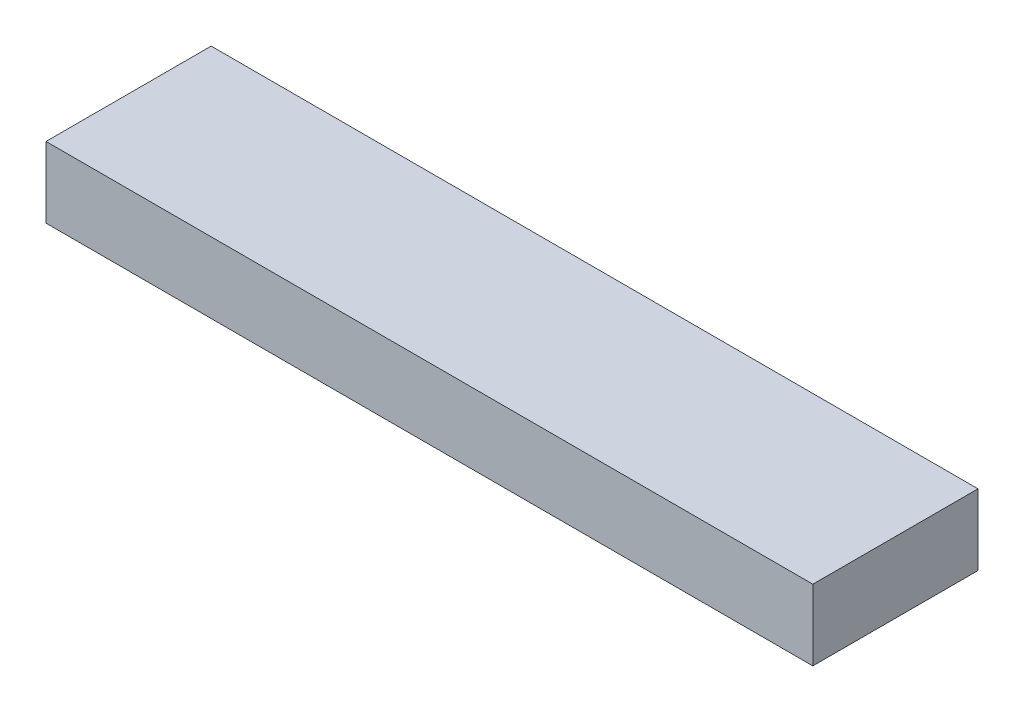
from build123d import *

# Parameters (mm, degrees)
SKETCH1_W           = 412.75
SKETCH1_H           = 88.9
BOSS_EXTRUDE1_DEPTH = 38.1


with BuildPart() as part:
    # Sketch1 → Boss-Extrude1 (new body)
    with BuildSketch(Plane(origin=(0, 0, 0), x_dir=(1, 0, 0), z_dir=(0, 1, 0))):
        with Locations((206.375, -44.45)):
            Rectangle(SKETCH1_W, SKETCH1_H)
    extrude(amount=BOSS_EXTRUDE1_DEPTH)


solid = part.part
